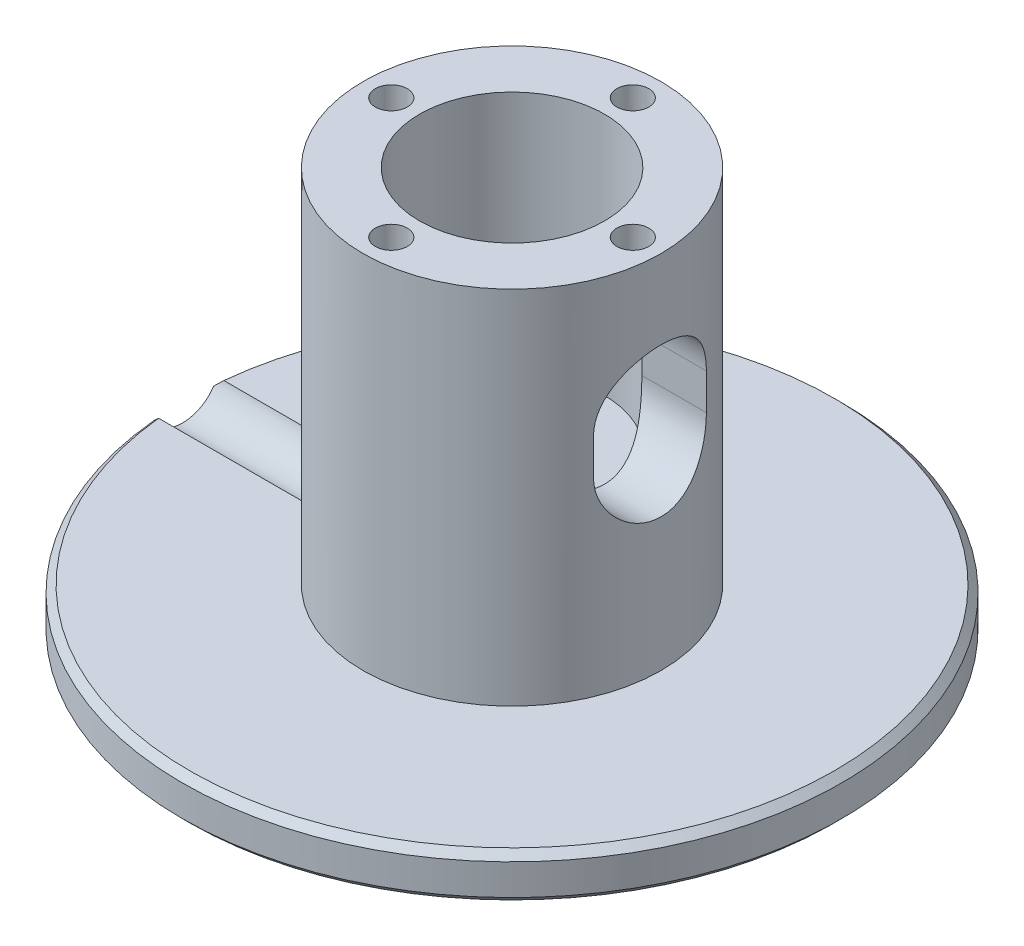
from build123d import *

# Parameters (mm, degrees)
SKETCH1_R           = 46.355
BOSS_EXTRUDE1_DEPTH = 6.35
SKETCH2_R           = 20.955
BOSS_EXTRUDE2_DEPTH = 50.8
CUT_EXTRUDE1_REACH  = 59.15
SKETCH3_3_R         = 13.0175
CUT_EXTRUDE2_DEPTH  = 34.29
CUT_EXTRUDE3_REACH  = 48.355
SKETCH5_5_R         = 2.2479
CUT_EXTRUDE7_DEPTH  = 9.525
CIRPATTERN1_COUNT   = 4
CUT_EXTRUDE8_REACH  = 95.345
SKETCH6_R           = 2.60985
SKETCH6_4_R         = 4.7625
CUT_EXTRUDE9_DEPTH  = 32.72
CHAMFER1_SIZE       = 1


with BuildPart() as part:
    # Sketch1 → Boss-Extrude1 (new body)
    with BuildSketch(Plane(origin=(0, 0, 0), x_dir=(1, 0, 0), z_dir=(0, 1, 0))):
        Circle(SKETCH1_R)
    extrude(amount=BOSS_EXTRUDE1_DEPTH)

    # Sketch2 → Boss-Extrude2 (add)
    with BuildSketch(Plane(origin=(0, 6.35, 0), x_dir=(1, 0, 0), z_dir=(0, 1, 0))):
        Circle(SKETCH2_R)
    extrude(amount=BOSS_EXTRUDE2_DEPTH)

    # Sketch3 → Cut-Extrude1 (cut, up to next)
    with BuildSketch(Plane(origin=(0, 57.15, 0), x_dir=(1, 0, 0), z_dir=(0, 1, 0)), mode=Mode.PRIVATE) as cut_extrude1_sk1:
        with BuildLine():
            Line((-2.84, -1.921572533), (-2.84, 1.921572533))
            ThreePointArc((-2.84, 1.921572533), (3.429, 0), (-2.84, -1.921572533))
        make_face()
    cut_extrude1_tool1 = extrude(cut_extrude1_sk1.sketch, amount=-CUT_EXTRUDE1_REACH, mode=Mode.PRIVATE) & part.part
    add(cut_extrude1_tool1.solids().sort_by_distance((0.133614, 57.15, 0))[0], mode=Mode.SUBTRACT)

    # Sketch3_3 → Cut-Extrude2 (cut)
    with BuildSketch(Plane(origin=(0, 57.15, 0), x_dir=(1, 0, 0), z_dir=(0, 1, 0))):
        Circle(SKETCH3_3_R)
    extrude(amount=-CUT_EXTRUDE2_DEPTH, mode=Mode.SUBTRACT)

    # Sketch4 → Cut-Extrude3 (cut, up to next)
    with BuildSketch(Plane(origin=(0, 0, 0), x_dir=(0, 0, -1), z_dir=(1, 0, 0)), mode=Mode.PRIVATE) as cut_extrude3_sk1:
        with BuildLine():
            ThreePointArc((7.9375, 33.02), (0, 25.0825), (-7.9375, 33.02))
            Line((-7.9375, 33.02), (-7.9375, 38.1))
            ThreePointArc((-7.9375, 38.1), (0, 46.0375), (7.9375, 38.1))
            Line((7.9375, 38.1), (7.9375, 33.02))
        make_face()
    cut_extrude3_tool1 = extrude(cut_extrude3_sk1.sketch, amount=CUT_EXTRUDE3_REACH, mode=Mode.PRIVATE) & part.part
    add(cut_extrude3_tool1.solids().sort_by_distance((0, 35.56, 0))[0], mode=Mode.SUBTRACT)

    # Sketch5_5 → Cut-Extrude7 (cut)
    with BuildSketch(Plane.XZ.offset(-57.15)):
        with Locations((0, -16.98625)):
            Circle(SKETCH5_5_R)
    cut_extrude7 = extrude(amount=CUT_EXTRUDE7_DEPTH, mode=Mode.SUBTRACT)

    # CirPattern1: Cut-Extrude7 ×4 about axis
    cirpattern1_axis = Axis((0, 0, 0), (0, 1, 0))
    for i in range(1, CIRPATTERN1_COUNT):
        add(cut_extrude7.rotate(cirpattern1_axis, i * 360 / CIRPATTERN1_COUNT), mode=Mode.SUBTRACT)

    # Sketch6 → Cut-Extrude8 (cut, up to next)
    with BuildSketch(Plane(origin=(-46.99, 0, 0), x_dir=(0, 0, -1), z_dir=(1, 0, 0)), mode=Mode.PRIVATE) as cut_extrude8_sk1:
        with Locations((0, 7.62)):
            Circle(SKETCH6_R)
    cut_extrude8_tool1 = extrude(cut_extrude8_sk1.sketch, amount=CUT_EXTRUDE8_REACH, mode=Mode.PRIVATE) & part.part
    add(cut_extrude8_tool1.solids().sort_by_distance((-46.99, 7.62, 0))[0], mode=Mode.SUBTRACT)

    # Sketch6_4 → Cut-Extrude9 (cut)
    with BuildSketch(Plane(origin=(-46.99, 0, 0), x_dir=(0, 0, -1), z_dir=(1, 0, 0))):
        with Locations((0, 7.62)):
            Circle(SKETCH6_4_R)
    extrude(amount=CUT_EXTRUDE9_DEPTH, mode=Mode.SUBTRACT)

    # Chamfer1
    chamfer1_edges = [part.edges().sort_by_distance(p)[0] for p in [
        (-46.355, 0, 0),
        (2.297847054, 6.35, 46.298012095),
    ]]
    chamfer(chamfer1_edges, length=CHAMFER1_SIZE)


solid = part.part
